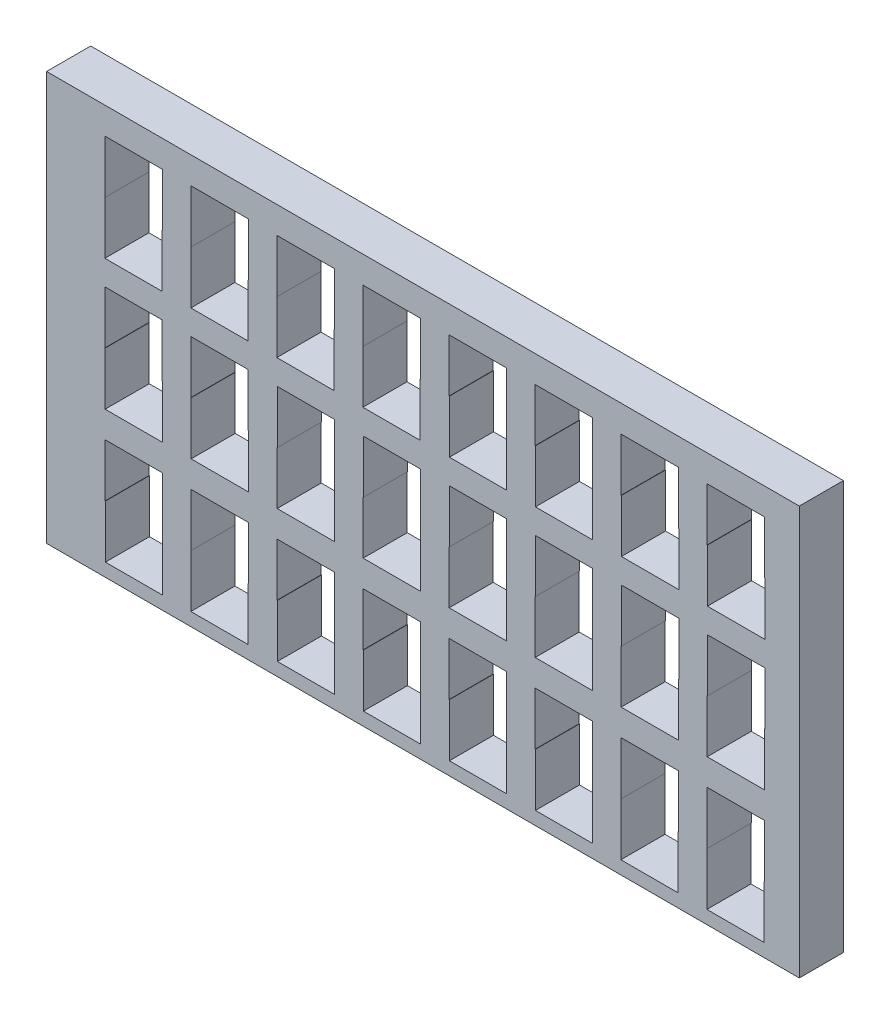
from build123d import *

# Parameters (mm, degrees)
SKETCH1_W           = 170.67
SKETCH1_H           = 92.67
BOSS_EXTRUDE3_DEPTH = 10


with BuildPart() as part:
    # Sketch1 → Boss-Extrude3 (new body)
    with BuildSketch(Plane.XY):
        with Locations((49.728369838, 28.496112047)):
            Rectangle(SKETCH1_W, SKETCH1_H)
        Polygon((-22.271785995, -14.851567408), (-22.271785995, -2.851567408), (-22.334139111, -2.851567408), (-22.334139111, 9.148432592), (-9.334139111, 9.148432592), (-9.334139111, -2.851567408), (-9.271785995, -2.851567408), (-9.271785995, -14.851567408), align=None, mode=Mode.SUBTRACT)
        Polygon((-2.896492227, -14.851567408), (-2.896492227, -2.851567408), (-2.834139111, -2.851567408), (-2.834139111, 9.148432592), (10.165860889, 9.148432592), (10.165860889, -2.851567408), (10.103507773, -2.851567408), (10.103507773, -14.851567408), align=None, mode=Mode.SUBTRACT)
        Polygon((16.665860889, -2.851567408), (16.665860889, 9.148432592), (29.665860889, 9.148432592), (29.665860889, -2.851567408), (29.728214005, -2.851567408), (29.728214005, -14.851567408), (16.728214005, -14.851567408), (16.728214005, -2.851567408), align=None, mode=Mode.SUBTRACT)
        Polygon((36.165860889, -2.851567408), (36.165860889, 9.148432592), (49.165860889, 9.148432592), (49.165860889, -2.851567408), (49.228214005, -2.851567408), (49.228214005, -14.851567408), (36.228214005, -14.851567408), (36.228214005, -2.851567408), align=None, mode=Mode.SUBTRACT)
        Polygon((-9.334139111, 27.148432592), (-9.334139111, 15.148432592), (-22.334139111, 15.148432592), (-22.334139111, 27.148432592), (-22.396492227, 27.148432592), (-22.396492227, 39.148432592), (-9.396492227, 39.148432592), (-9.396492227, 27.148432592), align=None, mode=Mode.SUBTRACT)
        Polygon((10.165860889, 27.148432592), (10.165860889, 15.148432592), (-2.834139111, 15.148432592), (-2.834139111, 27.148432592), (-2.896492227, 27.148432592), (-2.896492227, 39.148432592), (10.103507773, 39.148432592), (10.103507773, 27.148432592), align=None, mode=Mode.SUBTRACT)
        Polygon((29.728214005, 39.148432592), (29.728214005, 27.148432592), (29.665860889, 27.148432592), (29.665860889, 15.148432592), (16.665860889, 15.148432592), (16.665860889, 27.148432592), (16.728214005, 27.148432592), (16.728214005, 39.148432592), align=None, mode=Mode.SUBTRACT)
        Polygon((49.228214005, 39.148432592), (49.228214005, 27.148432592), (49.165860889, 27.148432592), (49.165860889, 15.148432592), (36.165860889, 15.148432592), (36.165860889, 27.148432592), (36.228214005, 27.148432592), (36.228214005, 39.148432592), align=None, mode=Mode.SUBTRACT)
        Polygon((55.665860889, 9.148432592), (68.665860889, 9.148432592), (68.665860889, -2.851567408), (68.728214005, -2.851567408), (68.728214005, -14.851567408), (55.728214005, -14.851567408), (55.728214005, -2.851567408), (55.665860889, -2.851567408), align=None, mode=Mode.SUBTRACT)
        Polygon((75.165860889, 9.148432592), (88.165860889, 9.148432592), (88.165860889, -2.851567408), (88.228214005, -2.851567408), (88.228214005, -14.851567408), (75.228214005, -14.851567408), (75.228214005, -2.851567408), (75.165860889, -2.851567408), align=None, mode=Mode.SUBTRACT)
        Polygon((94.603507773, -14.851567408), (94.603507773, -2.851567408), (94.665860889, -2.851567408), (94.665860889, 9.148432592), (107.665860889, 9.148432592), (107.665860889, -2.851567408), (107.603507773, -2.851567408), (107.603507773, -14.851567408), align=None, mode=Mode.SUBTRACT)
        Polygon((127.165860889, -2.851567408), (127.103507773, -2.851567408), (127.103507773, -14.851567408), (114.103507773, -14.851567408), (114.103507773, -2.851567408), (114.165860889, -2.851567408), (114.165860889, 9.148432592), (127.165860889, 9.148432592), align=None, mode=Mode.SUBTRACT)
        Polygon((68.728214005, 39.148432592), (68.728214005, 27.148432592), (68.665860889, 27.148432592), (68.665860889, 15.148432592), (55.665860889, 15.148432592), (55.665860889, 27.148432592), (55.728214005, 27.148432592), (55.728214005, 39.148432592), align=None, mode=Mode.SUBTRACT)
        Polygon((88.228214005, 39.148432592), (88.228214005, 27.148432592), (88.165860889, 27.148432592), (88.165860889, 15.148432592), (75.165860889, 15.148432592), (75.165860889, 27.148432592), (75.228214005, 27.148432592), (75.228214005, 39.148432592), align=None, mode=Mode.SUBTRACT)
        Polygon((94.665860889, 27.148432592), (94.728214005, 27.148432592), (94.728214005, 39.148432592), (107.728214005, 39.148432592), (107.728214005, 27.148432592), (107.665860889, 27.148432592), (107.665860889, 15.148432592), (94.665860889, 15.148432592), align=None, mode=Mode.SUBTRACT)
        Polygon((127.228214005, 39.148432592), (127.228214005, 27.148432592), (127.165860889, 27.148432592), (127.165860889, 15.148432592), (114.165860889, 15.148432592), (114.165860889, 27.148432592), (114.228214005, 27.148432592), (114.228214005, 39.148432592), align=None, mode=Mode.SUBTRACT)
        Polygon((-22.396492227, 44.753067208), (-22.396492227, 56.753067208), (-22.334139111, 56.753067208), (-22.334139111, 68.753067208), (-9.334139111, 68.753067208), (-9.334139111, 56.753067208), (-9.396492227, 56.753067208), (-9.396492227, 44.753067208), align=None, mode=Mode.SUBTRACT)
        Polygon((10.165860889, 56.753067208), (10.103507773, 56.753067208), (10.103507773, 44.753067208), (-2.896492227, 44.753067208), (-2.896492227, 56.753067208), (-2.834139111, 56.753067208), (-2.834139111, 68.753067208), (10.165860889, 68.753067208), align=None, mode=Mode.SUBTRACT)
        Polygon((16.603507773, 44.753067208), (16.603507773, 56.753067208), (16.665860889, 56.753067208), (16.665860889, 68.753067208), (29.665860889, 68.753067208), (29.665860889, 56.753067208), (29.603507773, 56.753067208), (29.603507773, 44.753067208), align=None, mode=Mode.SUBTRACT)
        Polygon((36.103507773, 44.753067208), (36.103507773, 56.753067208), (36.165860889, 56.753067208), (36.165860889, 68.753067208), (49.165860889, 68.753067208), (49.165860889, 56.753067208), (49.103507773, 56.753067208), (49.103507773, 44.753067208), align=None, mode=Mode.SUBTRACT)
        Polygon((55.665860889, 68.753067208), (68.665860889, 68.753067208), (68.665860889, 56.753067208), (68.728214005, 56.753067208), (68.728214005, 44.753067208), (55.728214005, 44.753067208), (55.728214005, 56.753067208), (55.665860889, 56.753067208), align=None, mode=Mode.SUBTRACT)
        Polygon((75.165860889, 68.753067208), (88.165860889, 68.753067208), (88.165860889, 56.753067208), (88.228214005, 56.753067208), (88.228214005, 44.753067208), (75.228214005, 44.753067208), (75.228214005, 56.753067208), (75.165860889, 56.753067208), align=None, mode=Mode.SUBTRACT)
        Polygon((94.665860889, 68.753067208), (107.665860889, 68.753067208), (107.665860889, 56.753067208), (107.728214005, 56.753067208), (107.728214005, 44.753067208), (94.728214005, 44.753067208), (94.728214005, 56.753067208), (94.665860889, 56.753067208), align=None, mode=Mode.SUBTRACT)
        Polygon((114.165860889, 56.753067208), (114.165860889, 68.753067208), (127.165860889, 68.753067208), (127.165860889, 56.753067208), (127.228214005, 56.753067208), (127.228214005, 44.753067208), (114.228214005, 44.753067208), (114.228214005, 56.753067208), align=None, mode=Mode.SUBTRACT)
    extrude(amount=BOSS_EXTRUDE3_DEPTH)


solid = part.part
